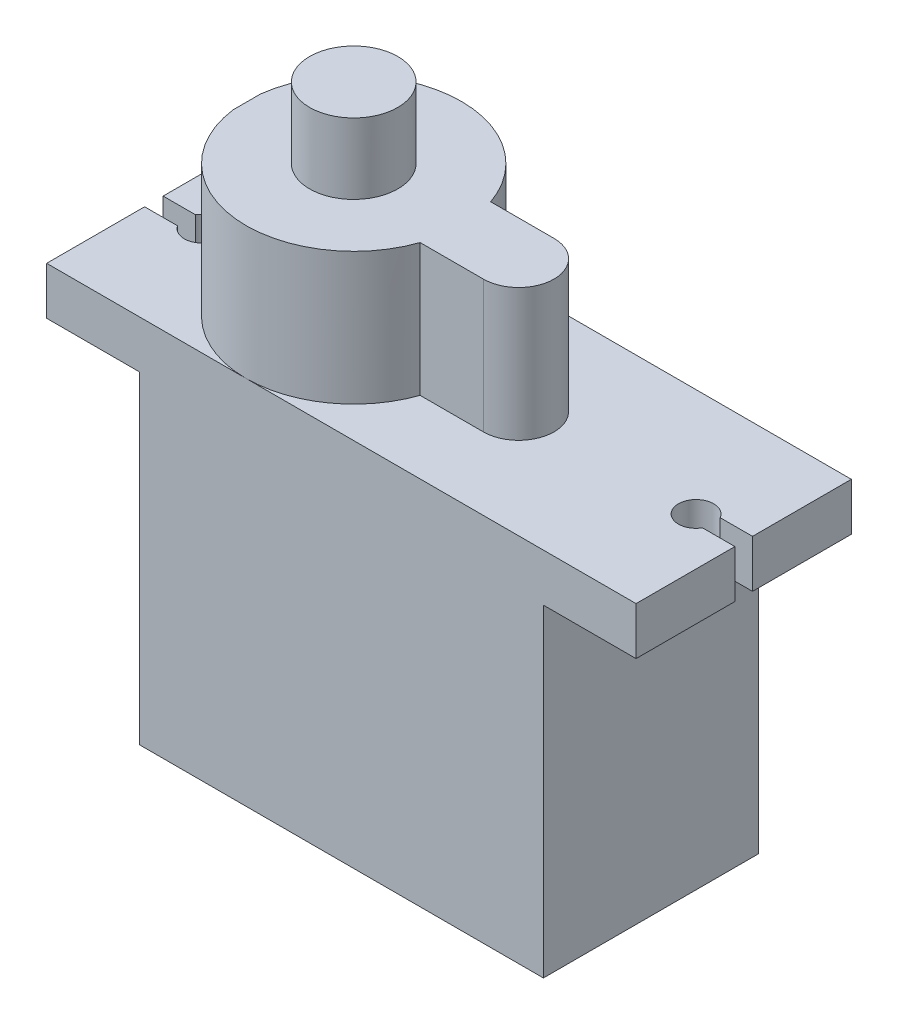
from build123d import *

# Parameters (mm, degrees)
BOSS_EXTRUDE1_DEPTH = 12.2
SKETCH2_R           = 1
CUT_EXTRUDE1_DEPTH  = 12.5
SKETCH3_R           = 2.5
BOSS_EXTRUDE2_DEPTH = 4
CUT_EXTRUDE2_DEPTH  = 7.5
SKETCH5_W           = 2.772136711
SKETCH5_H           = 1.05
SKETCH5_W_2         = 2.613565213
SKETCH5_H_2         = 1
CUT_EXTRUDE3_DEPTH  = 7.5


with BuildPart() as part:
    # Sketch1 → Boss-Extrude1 (new body)
    with BuildSketch(Plane.XY):
        Polygon((-5.25, 21), (-5.25, 18.3), (0, 18.3), (0, 0), (22.9, 0), (22.9, 18.3), (28.15, 18.3), (28.15, 21), (22.9, 21), (22.9, 28.5), (0, 28.5), (0, 21), align=None)
    extrude(amount=BOSS_EXTRUDE1_DEPTH)

    # Sketch2 → Cut-Extrude1 (cut)
    with BuildSketch(Plane(origin=(0, 21, 0), x_dir=(1, 0, 0), z_dir=(0, 1, 0))):
        with Locations((-2.55, -6.1)):
            Circle(SKETCH2_R)
        with Locations((25.45, -6.1)):
            Circle(SKETCH2_R)
    extrude(amount=-CUT_EXTRUDE1_DEPTH, mode=Mode.SUBTRACT)

    # Sketch3 → Boss-Extrude2 (add)
    with BuildSketch(Plane(origin=(0, 28.5, 0), x_dir=(1, 0, 0), z_dir=(0, 1, 0))):
        with Locations((6.05, -6.1)):
            Circle(SKETCH3_R)
    extrude(amount=BOSS_EXTRUDE2_DEPTH)

    # Sketch4 → Cut-Extrude2 (cut)
    with BuildSketch(Plane(origin=(0, 28.5, 0), x_dir=(1, 0, 0), z_dir=(0, 1, 0))):
        with BuildLine():
            Line((6.050000045, 0), (0, 0))
            Line((0, 0), (0, -5.320577137))
            ThreePointArc((0, -5.320577137), (2.021630587, -1.519362504), (6.050000045, 0))
        make_face()
        with BuildLine():
            Line((22.9, 0), (6.050000045, 0))
            ThreePointArc((6.050000045, 0), (9.58624096, -1.129587555), (11.812811814, -4.1))
            Line((11.812811814, -4.1), (15.4, -4.1))
            ThreePointArc((15.4, -4.1), (17.4, -6.1), (15.4, -8.1))
            Line((15.4, -8.1), (11.812811814, -8.1))
            ThreePointArc((11.812811814, -8.1), (9.586240956, -11.070412448), (6.050000034, -12.2))
            Line((6.050000034, -12.2), (22.9, -12.2))
            Line((22.9, -12.2), (22.9, 0))
        make_face()
        with BuildLine():
            ThreePointArc((6.050000034, -12.2), (2.021630582, -10.680637492), (0, -6.879422863))
            Line((0, -6.879422863), (0, -12.2))
            Line((0, -12.2), (6.050000034, -12.2))
        make_face()
    extrude(amount=-CUT_EXTRUDE2_DEPTH, mode=Mode.SUBTRACT)

    # Sketch5 → Cut-Extrude3 (cut)
    with BuildSketch(Plane(origin=(0, 21, 0), x_dir=(1, 0, 0), z_dir=(0, 1, 0))):
        with Locations((-3.863931645, -6.125)):
            Rectangle(SKETCH5_W, SKETCH5_H)
        with Locations((26.843217394, -6.1)):
            Rectangle(SKETCH5_W_2, SKETCH5_H_2)
    extrude(amount=-CUT_EXTRUDE3_DEPTH, mode=Mode.SUBTRACT)


solid = part.part
